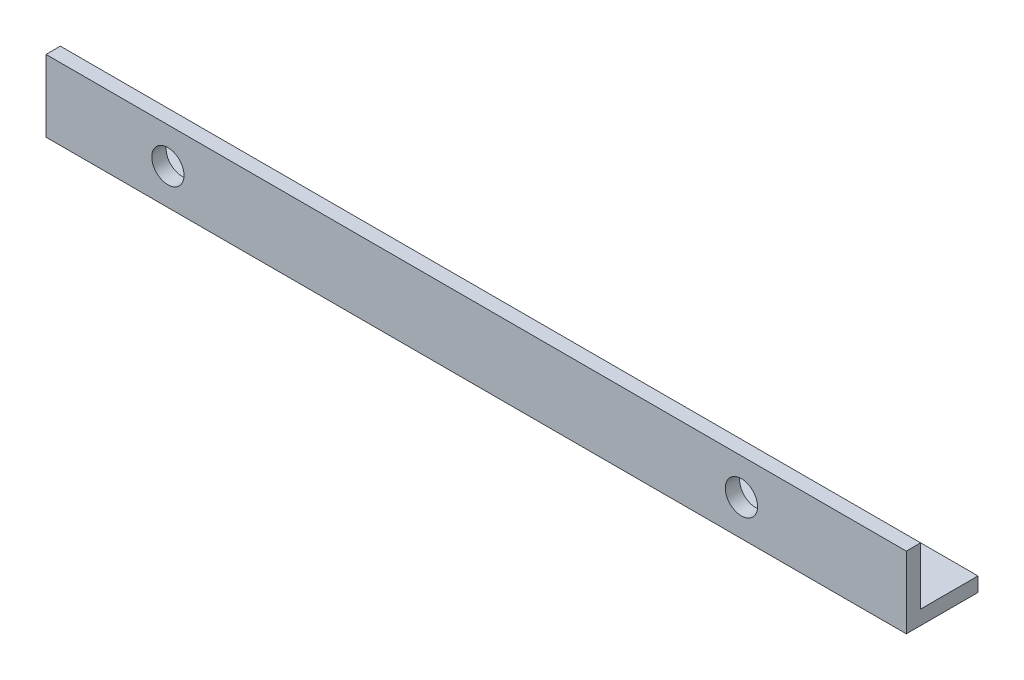
from build123d import *

# Parameters (mm, degrees)
EXTRUDE_1_DEPTH     = 120
CUT_EXTRUDE_1_REACH = 12
SKETCH_2_R          = 2.25
CUT_EXTRUDE_2_REACH = 12
SKETCH_3_R          = 2.25


with BuildPart() as part:
    # Эскиз1 → Бобышка-Вытянуть1 (new body)
    with BuildSketch(Plane(origin=(0, 0, 0), x_dir=(0, 0, -1), z_dir=(1, 0, 0))):
        Polygon((0, 0), (0, 10), (2, 10), (2, 2), (10, 2), (10, 0), align=None)
    extrude(amount=EXTRUDE_1_DEPTH)

    # Эскиз2 → Вырез-Вытянуть1 (cut, up to next)
    with BuildSketch(Plane.XY, mode=Mode.PRIVATE) as cut_extrude_1_sk1:
        with Locations((97, 5)):
            Circle(SKETCH_2_R)
    cut_extrude_1_tool1 = extrude(cut_extrude_1_sk1.sketch, amount=-CUT_EXTRUDE_1_REACH, mode=Mode.PRIVATE) & part.part
    add(cut_extrude_1_tool1.solids().sort_by_distance((97, 5, 0))[0], mode=Mode.SUBTRACT)
    # Эскиз2 → Вырез-Вытянуть1 (cut, up to next)
    with BuildSketch(Plane.XY, mode=Mode.PRIVATE) as cut_extrude_1_sk2:
        with Locations((17, 5)):
            Circle(SKETCH_2_R)
    cut_extrude_1_tool2 = extrude(cut_extrude_1_sk2.sketch, amount=-CUT_EXTRUDE_1_REACH, mode=Mode.PRIVATE) & part.part
    add(cut_extrude_1_tool2.solids().sort_by_distance((17, 5, 0))[0], mode=Mode.SUBTRACT)

    # Эскиз3 → Вырез-Вытянуть2 (cut, up to next)
    with BuildSketch(Plane.XZ, mode=Mode.PRIVATE) as cut_extrude_2_sk1:
        with Locations((103, -5)):
            Circle(SKETCH_3_R)
    cut_extrude_2_tool1 = extrude(cut_extrude_2_sk1.sketch, amount=-CUT_EXTRUDE_2_REACH, mode=Mode.PRIVATE) & part.part
    add(cut_extrude_2_tool1.solids().sort_by_distance((103, 0, -5))[0], mode=Mode.SUBTRACT)
    # Эскиз3 → Вырез-Вытянуть2 (cut, up to next)
    with BuildSketch(Plane.XZ, mode=Mode.PRIVATE) as cut_extrude_2_sk2:
        with Locations((23, -5)):
            Circle(SKETCH_3_R)
    cut_extrude_2_tool2 = extrude(cut_extrude_2_sk2.sketch, amount=-CUT_EXTRUDE_2_REACH, mode=Mode.PRIVATE) & part.part
    add(cut_extrude_2_tool2.solids().sort_by_distance((23, 0, -5))[0], mode=Mode.SUBTRACT)


solid = part.part
